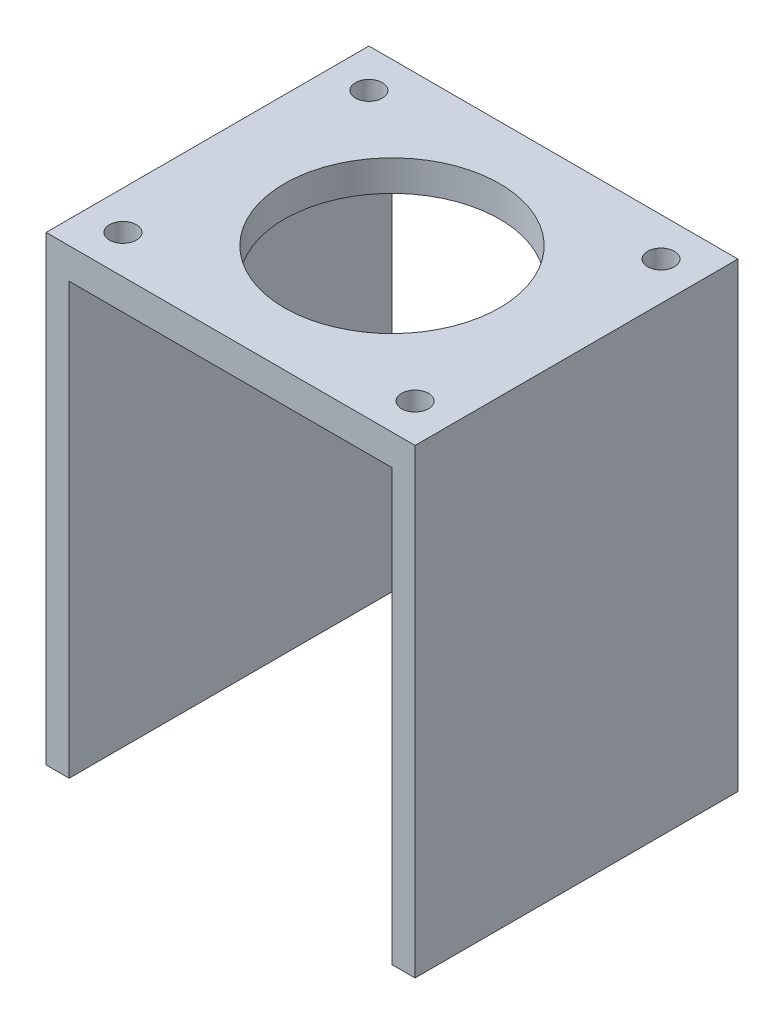
from build123d import *

# Parameters (mm, degrees)
BOSS_EXTRUDE1_DEPTH = 42
SKETCH2_R           = 1.75
SKETCH2_R_2         = 14
CUT_EXTRUDE1_DEPTH  = 61


with BuildPart() as part:
    # Sketch1 → Boss-Extrude1 (new body)
    with BuildSketch(Plane.XY):
        Polygon((-21, -30), (-21, 26), (21, 26), (21, -30), (24, -30), (24, 30), (-24, 30), (-24, -30), align=None)
    extrude(amount=BOSS_EXTRUDE1_DEPTH)

    # Sketch2 → Cut-Extrude1 (cut, through all)
    with BuildSketch(Plane(origin=(0, 30, 0), x_dir=(1, 0, 0), z_dir=(0, 1, 0))):
        with Locations((19, -37)):
            Circle(SKETCH2_R)
        with Locations((19, -5)):
            Circle(SKETCH2_R)
        with Locations((-19, -37)):
            Circle(SKETCH2_R)
        with Locations((-19, -5)):
            Circle(SKETCH2_R)
        with Locations((0, -21)):
            Circle(SKETCH2_R_2)
    extrude(amount=-CUT_EXTRUDE1_DEPTH, mode=Mode.SUBTRACT)


solid = part.part
